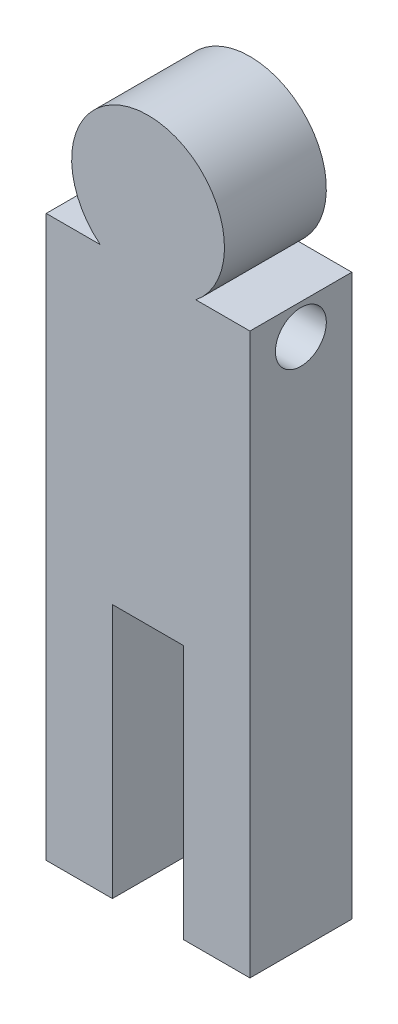
from build123d import *

# Parameters (mm, degrees)
SALIENTE_EXTRUIR1_DEPTH = 10
CROQUIS2_R              = 2.5
CORTAR_EXTRUIR1_DEPTH   = 21


with BuildPart() as part:
    # Croquis1 → Saliente-Extruir1 (new body)
    with BuildSketch(Plane.XY):
        with BuildLine():
            Line((-10, -15), (-10, -40))
            Line((-10, -40), (-3.5, -40))
            Line((-3.5, -40), (-3.5, -15))
            Line((-3.5, -15), (3.5, -15))
            Line((3.5, -15), (3.5, -40))
            Line((3.5, -40), (10, -40))
            Line((10, -40), (10, -15))
            Line((10, -15), (10, 15))
            Line((10, 15), (4.695324154, 15))
            ThreePointArc((4.695324154, 15), (0, 28.348412698), (-4.695324154, 15))
            Line((-4.695324154, 15), (-10, 15))
            Line((-10, 15), (-10, -15))
        make_face()
    extrude(amount=SALIENTE_EXTRUIR1_DEPTH)

    # Croquis2 → Cortar-Extruir1 (cut)
    with BuildSketch(Plane(origin=(10, 0, 0), x_dir=(0, 0, -1), z_dir=(1, 0, 0))):
        with Locations((-5, 12)):
            Circle(CROQUIS2_R)
    extrude(amount=-CORTAR_EXTRUIR1_DEPTH, mode=Mode.SUBTRACT)


solid = part.part
